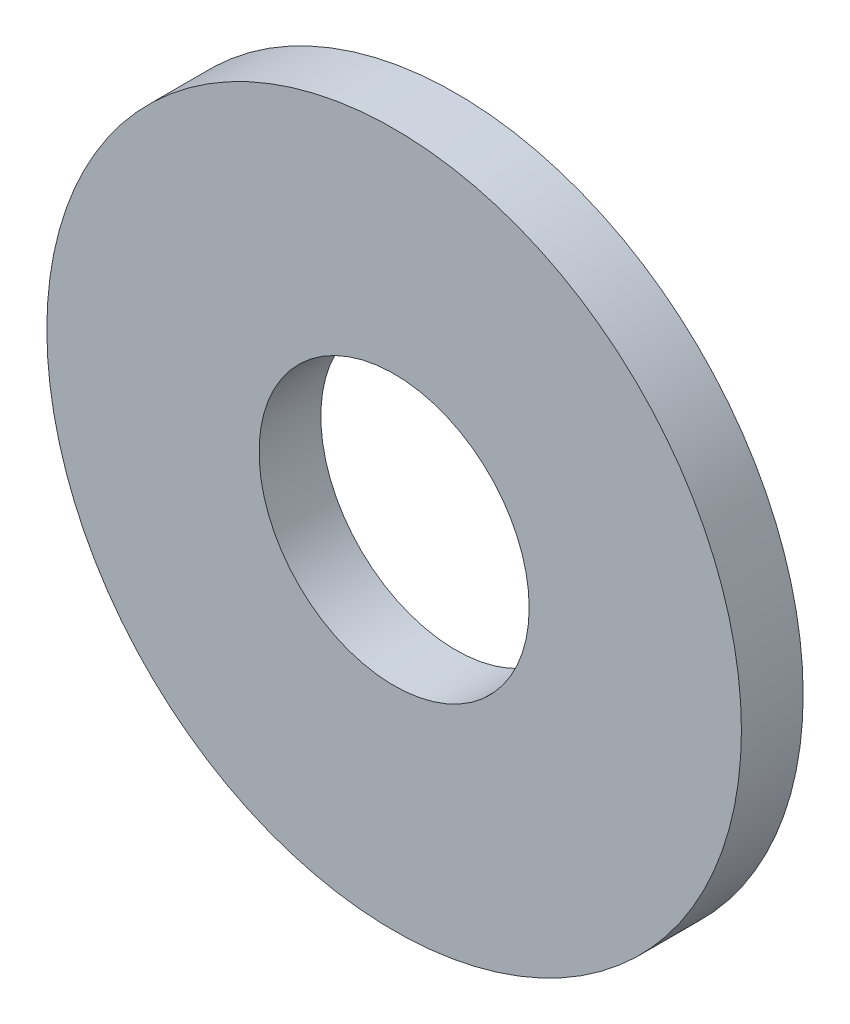
from build123d import *

# Parameters (mm, degrees)
ESQUISSE1_R      = 9
ESQUISSE1_R_2    = 3.5
EXTRUSION1_DEPTH = 1.6


with BuildPart() as part:
    # Esquisse1 → Extrusion1 (new body)
    with BuildSketch(Plane.XY):
        Circle(ESQUISSE1_R)
        Circle(ESQUISSE1_R_2, mode=Mode.SUBTRACT)
    extrude(amount=EXTRUSION1_DEPTH)


solid = part.part
